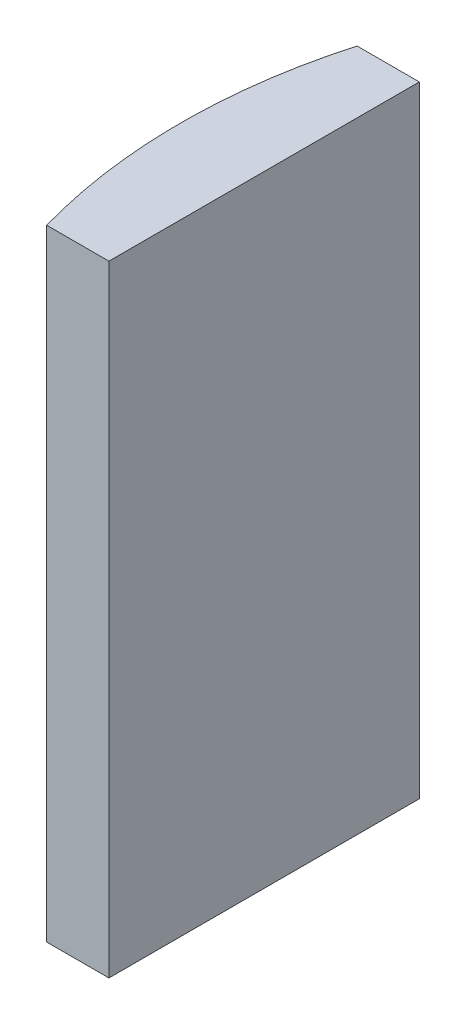
from build123d import *

# Parameters (mm, degrees)
EXTRUDE_1_DEPTH = 20


with BuildPart() as part:
    # 草图1 → 凸台-拉伸1 (new body)
    with BuildSketch(Plane(origin=(0, 0, 0), x_dir=(1, 0, 0), z_dir=(0, 1, 0))):
        with BuildLine():
            Line((-13.269278636, 5), (-11.264795665, 5))
            Line((-11.264795665, 5), (-11.264795665, -5))
            Line((-11.264795665, -5), (-13.269278636, -5))
            ThreePointArc((-13.269278636, -5), (-13.964795665, 0), (-13.269278636, 5))
        make_face()
    extrude(amount=EXTRUDE_1_DEPTH)


solid = part.part
